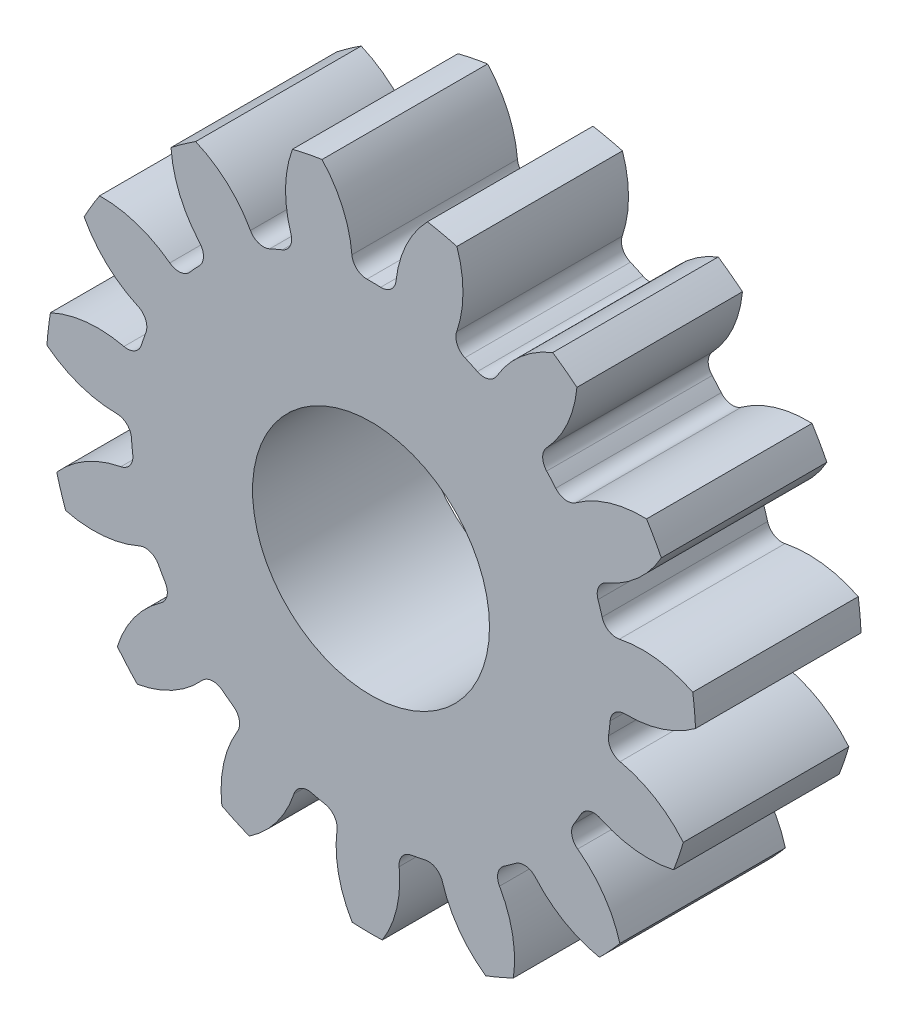
from build123d import *

# Parameters (mm, degrees)
SKETCH3_R         = 21.59
GEARBODY_DEPTH    = 11
TOOTHCUT_DEPTH    = 12
CIRPATTERN1_COUNT = 15
BOREDIA_R         = 7.874
BORE_DEPTH        = 12700


with BuildPart() as part:
    # Sketch3 → gearBody (new body)
    with BuildSketch(Plane.XY):
        Circle(SKETCH3_R)
    extrude(amount=GEARBODY_DEPTH)

    # Sketch2 → toothCut (cut, through all)
    with BuildSketch(Plane.XY):
        with BuildLine():
            ThreePointArc((15.783846764, -2.304552616), (15.843293638, -1.852249483), (15.889781974, -1.39843136))
            ThreePointArc((15.889781974, -1.39843136), (16.213055843, -0.751556907), (16.890861518, -0.499501321))
            ThreePointArc((16.890861518, -0.499501321), (20.504912911, 0.340315353), (23.283949955, 2.798691365))
            ThreePointArc((23.283949955, 2.798691365), (23.292901215, -2.723187818), (22.010467945, -8.09409042))
            ThreePointArc((22.010467945, -8.09409042), (19.873444675, -5.060974685), (16.550574786, -3.410158156))
            ThreePointArc((16.550574786, -3.410158156), (15.949189176, -3.008551507), (15.783846764, -2.304552616))
        make_face()
    toothcut = extrude(amount=TOOTHCUT_DEPTH, mode=Mode.SUBTRACT)

    # CirPattern1: toothCut ×15 about axis
    cirpattern1_axis = Axis((0, 0, 0), (0, 0, 1))
    for i in range(1, CIRPATTERN1_COUNT):
        add(toothcut.rotate(cirpattern1_axis, i * 360 / CIRPATTERN1_COUNT), mode=Mode.SUBTRACT)

    # boreDia → bore (cut, symmetric)
    with BuildSketch(Plane.XY):
        Circle(BOREDIA_R)
    extrude(amount=BORE_DEPTH, both=True, mode=Mode.SUBTRACT)


solid = part.part
